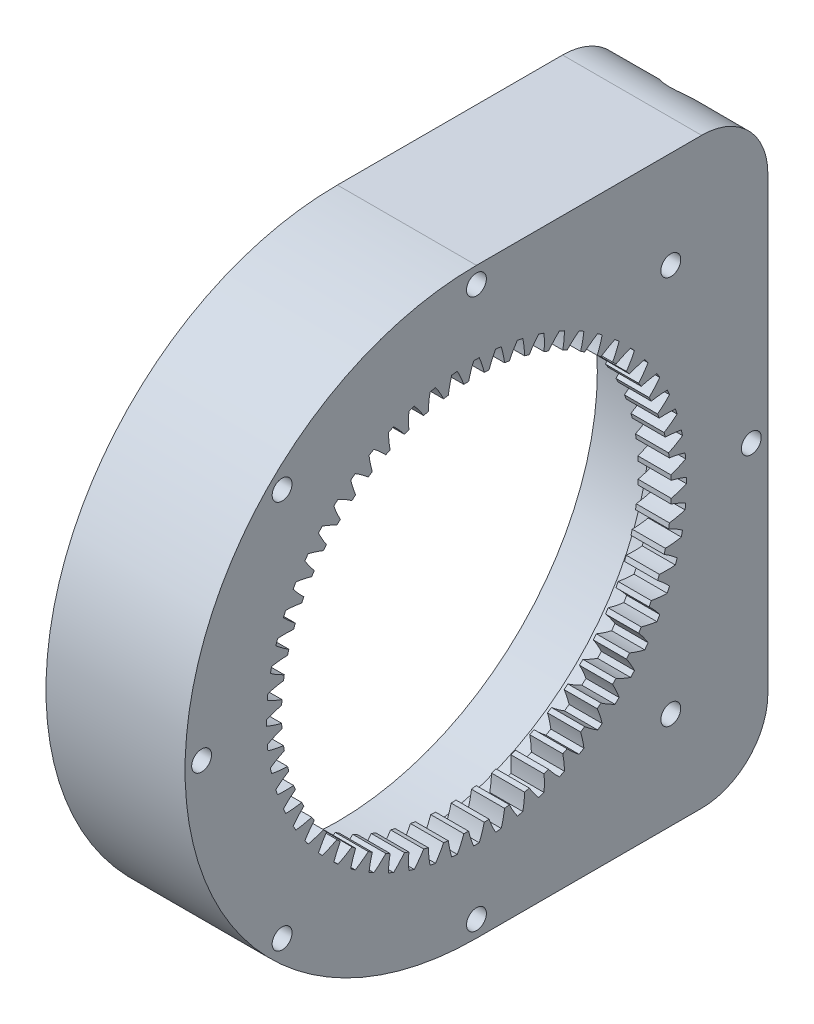
from build123d import *
from OCP.BRepFilletAPI import BRepFilletAPI_MakeChamfer

# Parameters (mm, degrees)
BASPROSKE_W         = 5
BASPROSKE_H         = 14.565
TOOTHCUT_DEPTH      = 63.42595614
TEETHCUTS_COUNT     = 60
SKETCH4_R           = 44
SKETCH4_R_2         = 39.25
BOSS_EXTRUDE3_DEPTH = 16
BOSS_EXTRUDE5_DEPTH = 21
BOSS_EXTRUDE6_DEPTH = 21
FILLET1_R           = 10
SKETCH14_R          = 39.25
SKETCH14_R_2        = 37.25
BOSS_EXTRUDE7_DEPTH = 6
SKETCH15_R          = 4.25
CUT_EXTRUDE1_DEPTH  = 20
CHAMFER1_SIZE       = 10
CHAMFER1_SIZE2      = 0.174550649
SKETCH16_R          = 1.5
CUT_EXTRUDE3_DEPTH  = 30
CIRPATTERN1_COUNT   = 8


with BuildPart() as part:
    # BasProSke → Base-Revolve (revolve)
    with BuildSketch(Plane(origin=(0, 0, 0), x_dir=(1, 0, 0), z_dir=(0, 1, 0)), mode=Mode.PRIVATE) as base_revolve_sk:
        with Locations((2.5, 36.7175)):
            Rectangle(BASPROSKE_W, BASPROSKE_H)
    revolve(base_revolve_sk.sketch.rotate(Axis((-10, 0, 0), (1, 0, 0)), 180), axis=Axis((-10, 0, 0), (1, 0, 0)))

    # TooCutSke → ToothCut (cut, through all)
    with BuildSketch(Plane(origin=(0, 0, 0), x_dir=(0, 0, -1), z_dir=(1, 0, 0))):
        with BuildLine():
            ThreePointArc((1.182891501, 29.385801671), (0.850504168, 30.566654642), (0.424126801, 31.71691436))
            ThreePointArc((0.424126801, 31.71691436), (0, 31.71975), (-0.424126801, 31.71691436))
            ThreePointArc((-0.424126801, 31.71691436), (-0.850504168, 30.566654642), (-1.182891501, 29.385801671))
            ThreePointArc((-1.182891501, 29.385801671), (0, 29.4096), (1.182891501, 29.385801671))
        make_face()
    toothcut = extrude(amount=TOOTHCUT_DEPTH, mode=Mode.SUBTRACT)

    # TeethCuts: ToothCut ×60 about axis
    teethcuts_axis = Axis((0, 0, 0), (1, 0, 0))
    for i in range(1, TEETHCUTS_COUNT):
        add(toothcut.rotate(teethcuts_axis, i * 360 / TEETHCUTS_COUNT), mode=Mode.SUBTRACT)

    # Sketch4 → Boss-Extrude3 (add)
    with BuildSketch(Plane.ZY):
        Circle(SKETCH4_R)
        Circle(SKETCH4_R_2, mode=Mode.SUBTRACT)
    extrude(amount=BOSS_EXTRUDE3_DEPTH)

    # Sketch7 → Boss-Extrude5 (add)
    with BuildSketch(Plane(origin=(5, 0, 0), x_dir=(0, 0, -1), z_dir=(1, 0, 0))):
        with BuildLine():
            Line((0, 44), (44, 44))
            Line((44, 44), (44, 0))
            ThreePointArc((44, 0), (31.112698372, 31.112698372), (0, 44))
        make_face()
    extrude(amount=-BOSS_EXTRUDE5_DEPTH)

    # Sketch10 → Boss-Extrude6 (add)
    with BuildSketch(Plane(origin=(5, 0, 0), x_dir=(0, 0, -1), z_dir=(1, 0, 0))):
        with BuildLine():
            Line((0, -44), (44, -44))
            Line((44, -44), (44, 0))
            ThreePointArc((44, 0), (31.112698372, -31.112698372), (0, -44))
        make_face()
    extrude(amount=-BOSS_EXTRUDE6_DEPTH)

    # Fillet1
    fillet1_edges = [part.edges().sort_by_distance(p)[0] for p in [
        (-5.5, 44, -44),
        (-5.5, -44, -44),
    ]]
    fillet(fillet1_edges, radius=FILLET1_R)

    # Sketch14 → Boss-Extrude7 (add)
    with BuildSketch(Plane.ZY):
        Circle(SKETCH14_R)
        Circle(SKETCH14_R_2, mode=Mode.SUBTRACT)
    extrude(amount=BOSS_EXTRUDE7_DEPTH)

    # Sketch15 → Cut-Extrude1 (cut)
    with BuildSketch(Plane(origin=(0, 0, -44), x_dir=(-1, 0, 0), z_dir=(0, 0, -1))):
        with Locations((5.5, -38)):
            Circle(SKETCH15_R)
        with Locations((5.5, 38)):
            Circle(SKETCH15_R)
    extrude(amount=-CUT_EXTRUDE1_DEPTH, mode=Mode.SUBTRACT)

    # Chamfer1: one chamfer whose edges measure the first distance from different faces: ONE call of the kernel's chamfer builder (chamfer() names one face for all edges)
    chamfer1_edges_1 = [part.edges().sort_by_distance(p)[0] for p in [
        (-1.25, -38, -24),
    ]]
    chamfer1_side_1 = [part.faces().sort_by_distance(p)[0] for p in [
        (-1.25, -38, -34),
    ]]
    chamfer1_edges_2 = [part.edges().sort_by_distance(p)[0] for p in [
        (-1.25, 38, -24),
    ]]
    chamfer1_side_2 = [part.faces().sort_by_distance(p)[0] for p in [
        (-1.25, 38, -34),
    ]]
    chamfer1 = BRepFilletAPI_MakeChamfer(part.part.solid().wrapped)
    for e in chamfer1_edges_1:
        chamfer1.Add(CHAMFER1_SIZE, CHAMFER1_SIZE2, e.wrapped, chamfer1_side_1[0].wrapped)  # the first distance lies on this face
    for e in chamfer1_edges_2:
        chamfer1.Add(CHAMFER1_SIZE, CHAMFER1_SIZE2, e.wrapped, chamfer1_side_2[0].wrapped)  # the first distance lies on this face
    add(Compound.cast(chamfer1.Shape()), mode=Mode.REPLACE)

    # Sketch16 → Cut-Extrude3 (cut)
    with BuildSketch(Plane.ZY.offset(16)):
        with Locations((41.5, 0)):
            Circle(SKETCH16_R)
    cut_extrude3 = extrude(amount=-CUT_EXTRUDE3_DEPTH, mode=Mode.SUBTRACT)

    # CirPattern1: Cut-Extrude3 ×8 about axis
    cirpattern1_axis = Axis((0, 0, 0), (1, 0, 0))
    for i in range(1, CIRPATTERN1_COUNT):
        add(cut_extrude3.rotate(cirpattern1_axis, i * 360 / CIRPATTERN1_COUNT), mode=Mode.SUBTRACT)


solid = part.part
